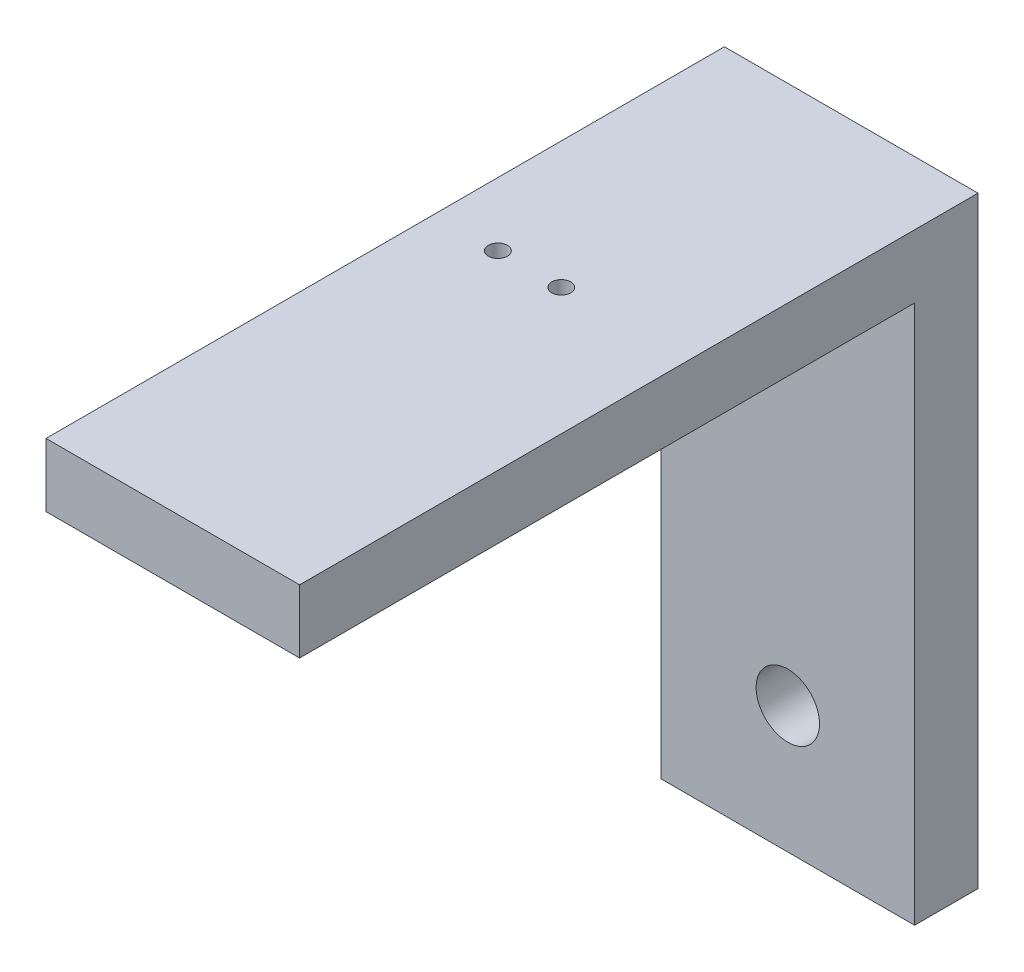
from build123d import *

# Parameters (mm, degrees)
SKETCH_4_W               = 40
SKETCH_4_H               = 40
EXTRUDE_1_DEPTH          = 10
SKETCH_1_R               = 5
CUT_EXTRUDE_1_DEPTH      = 19
SKETCH_5_W               = 40
SKETCH_5_H               = 10
EXTRUDE_2_DEPTH          = 55
SKETCH_6_W               = 40
SKETCH_6_H               = 10
EXTRUDE_3_DEPTH          = 97
SKETCH_7_R               = 1.5
CUT_EXTRUDE_2_DEPTH      = 17
PATTERN_LINEAR_1_COUNT   = 2
PATTERN_LINEAR_1_PITCH   = 10
SKETCH_10_R              = 1
EXTRUDE_5_DEPTH          = 2
PATTERN_CIRCULAR_3_COUNT = 4
DRAFT_2_ANGLE            = 15
DRAFT_3_ANGLE            = 15
DRAFT_4_ANGLE            = 15
DRAFT_5_ANGLE            = 15


with BuildPart() as part:
    # 草图4 → 凸台-拉伸1 (new body)
    with BuildSketch(Plane.XY):
        Rectangle(SKETCH_4_W, SKETCH_4_H)
    extrude(amount=EXTRUDE_1_DEPTH)

    # 草图1 → 切除-拉伸1 (cut)
    with BuildSketch(Plane.XY):
        Circle(SKETCH_1_R)
    extrude(amount=CUT_EXTRUDE_1_DEPTH, mode=Mode.SUBTRACT)

    # 草图5 → 凸台-拉伸2 (add)
    with BuildSketch(Plane(origin=(0, 20, 0), x_dir=(1, 0, 0), z_dir=(0, 1, 0))):
        with Locations((0, -5)):
            Rectangle(SKETCH_5_W, SKETCH_5_H)
    extrude(amount=EXTRUDE_2_DEPTH)

    # 草图6 → 凸台-拉伸3 (add)
    with BuildSketch(Plane.XY.offset(10)):
        with Locations((0, 70)):
            Rectangle(SKETCH_6_W, SKETCH_6_H)
    extrude(amount=EXTRUDE_3_DEPTH)

    # 草图7 → 切除-拉伸2 (cut)
    with BuildSketch(Plane(origin=(0, 75, 0), x_dir=(1, 0, 0), z_dir=(0, 1, 0))):
        with Locations((0, -45.729405638)):
            Circle(SKETCH_7_R)
    cut_extrude_2 = extrude(amount=-CUT_EXTRUDE_2_DEPTH, mode=Mode.SUBTRACT)

    # 阵列(线性)1: 切除-拉伸2 ×2
    with Locations(*[(-i * PATTERN_LINEAR_1_PITCH, 0, 0) for i in range(1, PATTERN_LINEAR_1_COUNT)]):
        add(cut_extrude_2, mode=Mode.SUBTRACT)

    # 草图10 → 凸台-拉伸5 (add)
    with BuildSketch(Plane.XY):
        with Locations((0, -10.379430626)):
            Circle(SKETCH_10_R)
    extrude_5 = extrude(amount=-EXTRUDE_5_DEPTH)

    # 阵列(圆周)3: 凸台-拉伸5 ×4 about axis
    pattern_circular_3_axis = Axis((0, 0, 0), (0, 0, 1))
    for i in range(1, PATTERN_CIRCULAR_3_COUNT):
        add(extrude_5.rotate(pattern_circular_3_axis, i * 360 / PATTERN_CIRCULAR_3_COUNT))

    # 拔模2
    draft_2_faces = [part.faces().sort_by_distance(p)[0] for p in [
        (-1, -10.379430626, -1),
    ]]
    draft(draft_2_faces, Plane(origin=(0, -10.379430626, -2), x_dir=(-1, 0, 0), z_dir=(0, 0, -1)), DRAFT_2_ANGLE)

    # 拔模3
    draft_3_faces = [part.faces().sort_by_distance(p)[0] for p in [
        (10.379430626, -1, -1),
    ]]
    draft(draft_3_faces, Plane(origin=(10.379430626, 0, -2), x_dir=(-1, 0, 0), z_dir=(0, 0, -1)), DRAFT_3_ANGLE)

    # 拔模4
    draft_4_faces = [part.faces().sort_by_distance(p)[0] for p in [
        (1, 10.379430626, -1),
    ]]
    draft(draft_4_faces, Plane(origin=(0, 10.379430626, -2), x_dir=(-1, 0, 0), z_dir=(0, 0, -1)), DRAFT_4_ANGLE)

    # 拔模5
    draft_5_faces = [part.faces().sort_by_distance(p)[0] for p in [
        (-10.379430626, 1, -1),
    ]]
    draft(draft_5_faces, Plane(origin=(-10.379430626, 0, -2), x_dir=(-1, 0, 0), z_dir=(0, 0, -1)), DRAFT_5_ANGLE)


solid = part.part
